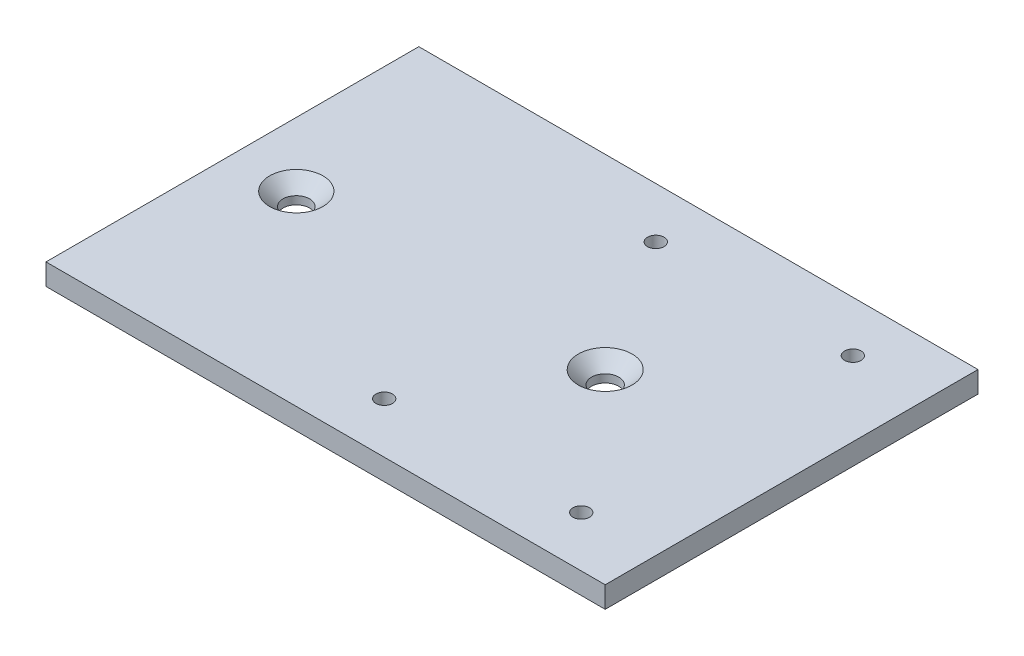
from build123d import *

# Parameters (mm, degrees)
SKETCH_1_W          = 45
SKETCH_1_H          = 70
SKETCH_1_R          = 1.55
EXTRUDE_1_DEPTH     = 4
SKETCH_3_W          = 70
SKETCH_3_H          = 4
EXTRUDE_3_DEPTH     = 40
SKETCH_4_R          = 2.55
CUT_EXTRUDE_1_DEPTH = 6
CHAMFER_1_SIZE      = 2.5
SKETCH_5_W          = 70
SKETCH_5_H          = 4
EXTRUDE_4_DEPTH     = 10
SKETCH_6_W          = 70
SKETCH_6_H          = 4
EXTRUDE_5_DEPTH     = 10
SKETCH_7_R          = 2.5
CUT_EXTRUDE_2_DEPTH = 10
CHAMFER_3_SIZE      = 2.5


with BuildPart() as part:
    # 草图1 → 凸台-拉伸1 (new body)
    with BuildSketch(Plane(origin=(0, 0, 0), x_dir=(1, 0, 0), z_dir=(0, 1, 0))):
        Rectangle(SKETCH_1_W, SKETCH_1_H)
        with Locations((18.5, 25.5)):
            Circle(SKETCH_1_R, mode=Mode.SUBTRACT)
        with Locations((-18.5, 25.5)):
            Circle(SKETCH_1_R, mode=Mode.SUBTRACT)
        with Locations((-18.5, -25.5)):
            Circle(SKETCH_1_R, mode=Mode.SUBTRACT)
        with Locations((18.5, -25.5)):
            Circle(SKETCH_1_R, mode=Mode.SUBTRACT)
    extrude(amount=EXTRUDE_1_DEPTH)

    # 草图3 → 凸台-拉伸3 (add)
    with BuildSketch(Plane.ZY.offset(22.5)):
        with Locations((0, 2)):
            Rectangle(SKETCH_3_W, SKETCH_3_H)
    extrude(amount=EXTRUDE_3_DEPTH)

    # 草图4 → 切除-拉伸1 (cut)
    with BuildSketch(Plane(origin=(0, 4, 0), x_dir=(1, 0, 0), z_dir=(0, 1, 0))):
        with Locations((-2.5, 0)):
            Circle(SKETCH_4_R)
    extrude(amount=-CUT_EXTRUDE_1_DEPTH, mode=Mode.SUBTRACT)

    # 倒角1
    chamfer_1_edges = [part.edges().sort_by_distance(p)[0] for p in [
        (-5.05, 4, 0),
    ]]
    chamfer(chamfer_1_edges, length=CHAMFER_1_SIZE)

    # 草图5 → 凸台-拉伸4 (add)
    with BuildSketch(Plane(origin=(22.5, 0, 0), x_dir=(0, 0, -1), z_dir=(1, 0, 0))):
        with Locations((0, 2)):
            Rectangle(SKETCH_5_W, SKETCH_5_H)
    extrude(amount=EXTRUDE_4_DEPTH)

    # 草图6 → 凸台-拉伸5 (add)
    with BuildSketch(Plane.ZY.offset(62.5)):
        with Locations((0, 2)):
            Rectangle(SKETCH_6_W, SKETCH_6_H)
    extrude(amount=EXTRUDE_5_DEPTH)

    # 草图7 → 切除-拉伸2 (cut)
    with BuildSketch(Plane(origin=(0, 4, 0), x_dir=(1, 0, 0), z_dir=(0, 1, 0))):
        with Locations((-60.5, 0)):
            Circle(SKETCH_7_R)
    extrude(amount=-CUT_EXTRUDE_2_DEPTH, mode=Mode.SUBTRACT)

    # 倒角3
    chamfer_3_edges = [part.edges().sort_by_distance(p)[0] for p in [
        (-63, 4, 0),
    ]]
    chamfer(chamfer_3_edges, length=CHAMFER_3_SIZE)


solid = part.part
